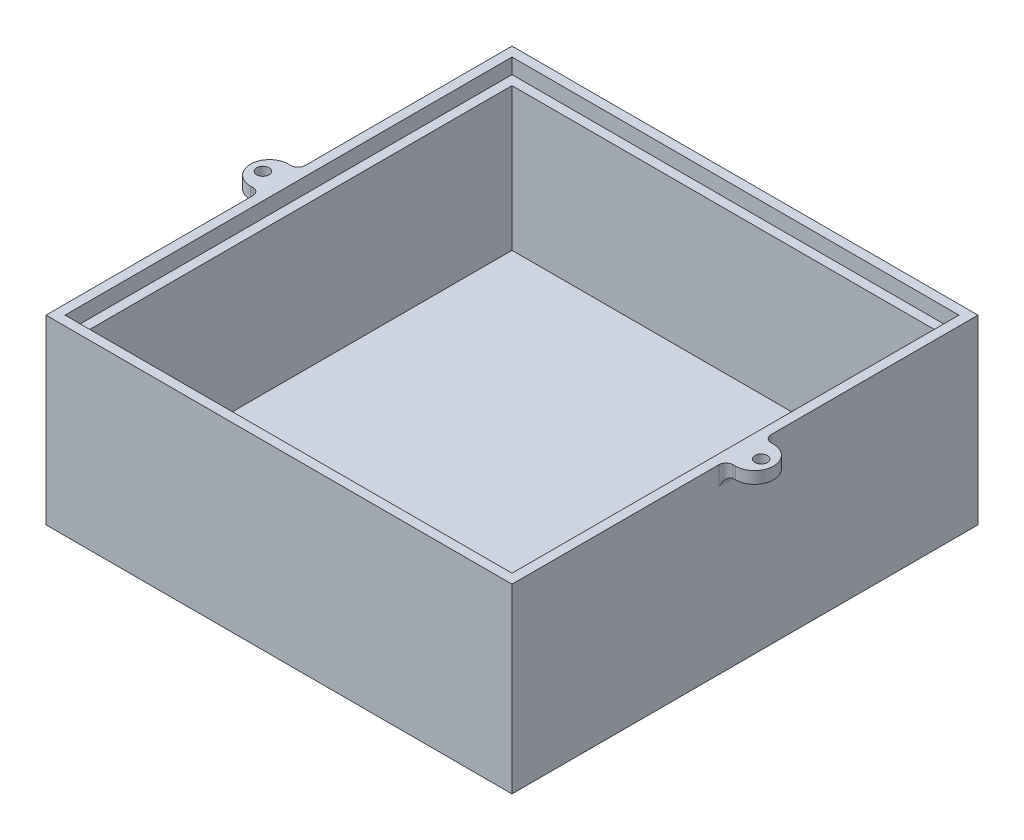
from build123d import *

# Parameters (mm, degrees)
SKETCH1_W           = 98
SKETCH1_H           = 98
BOSS_EXTRUDE1_DEPTH = 40
SKETCH2_W           = 94
SKETCH2_H           = 94
CUT_EXTRUDE1_DEPTH  = 5
SKETCH3_W           = 90
SKETCH3_H           = 90
CUT_EXTRUDE2_DEPTH  = 30
SKETCH4_W           = 98
SKETCH4_H           = 98
SKETCH4_W_2         = 94
SKETCH4_H_2         = 94
CUT_EXTRUDE3_DEPTH  = 1.8
SKETCH5_R           = 1.3
BOSS_EXTRUDE2_DEPTH = 2.5
FILLET1_R           = 1.5
FILLET2_R           = 1.5


with BuildPart() as part:
    # Sketch1 → Boss-Extrude1 (new body)
    with BuildSketch(Plane(origin=(0, 0, 0), x_dir=(1, 0, 0), z_dir=(0, 1, 0))):
        Rectangle(SKETCH1_W, SKETCH1_H)
    extrude(amount=BOSS_EXTRUDE1_DEPTH)

    # Sketch2 → Cut-Extrude1 (cut)
    with BuildSketch(Plane(origin=(0, 40, 0), x_dir=(1, 0, 0), z_dir=(0, 1, 0))):
        Rectangle(SKETCH2_W, SKETCH2_H)
    extrude(amount=-CUT_EXTRUDE1_DEPTH, mode=Mode.SUBTRACT)

    # Sketch3 → Cut-Extrude2 (cut)
    with BuildSketch(Plane(origin=(0, 35, 0), x_dir=(1, 0, 0), z_dir=(0, 1, 0))):
        Rectangle(SKETCH3_W, SKETCH3_H)
    extrude(amount=-CUT_EXTRUDE2_DEPTH, mode=Mode.SUBTRACT)

    # Sketch4 → Cut-Extrude3 (cut)
    with BuildSketch(Plane(origin=(0, 40, 0), x_dir=(1, 0, 0), z_dir=(0, 1, 0))):
        Rectangle(SKETCH4_W, SKETCH4_H)
        Rectangle(SKETCH4_W_2, SKETCH4_H_2, mode=Mode.SUBTRACT)
    extrude(amount=-CUT_EXTRUDE3_DEPTH, mode=Mode.SUBTRACT)

    # Sketch5 → Boss-Extrude2 (add)
    with BuildSketch(Plane(origin=(0, 38.2, 0), x_dir=(1, 0, 0), z_dir=(0, 1, 0))):
        with BuildLine():
            Line((-49, 4), (-51, 4))
            ThreePointArc((-51, 4), (-55, 0), (-51, -4))
            Line((-51, -4), (-49, -4))
            Line((-49, -4), (-49, 4))
        make_face()
        with Locations((-52.4, 0)):
            Circle(SKETCH5_R, mode=Mode.SUBTRACT)
        with BuildLine():
            Line((49, 4), (49, -4))
            Line((49, -4), (51, -4))
            ThreePointArc((51, -4), (55, 0), (51, 4))
            Line((51, 4), (49, 4))
        make_face()
        with Locations((52.4, 0)):
            Circle(SKETCH5_R, mode=Mode.SUBTRACT)
    extrude(amount=-BOSS_EXTRUDE2_DEPTH)

    # Fillet1
    fillet1_edges = [part.edges().sort_by_distance(p)[0] for p in [
        (-49, 35.7, 0),
        (-49, 36.95, -4),
        (-49, 36.95, 4),
    ]]
    fillet(fillet1_edges, radius=FILLET1_R)

    # Fillet2
    fillet2_edges = [part.edges().sort_by_distance(p)[0] for p in [
        (49, 36.95, -4),
        (49, 35.7, 0),
        (49, 36.95, 4),
    ]]
    fillet(fillet2_edges, radius=FILLET2_R)


solid = part.part
